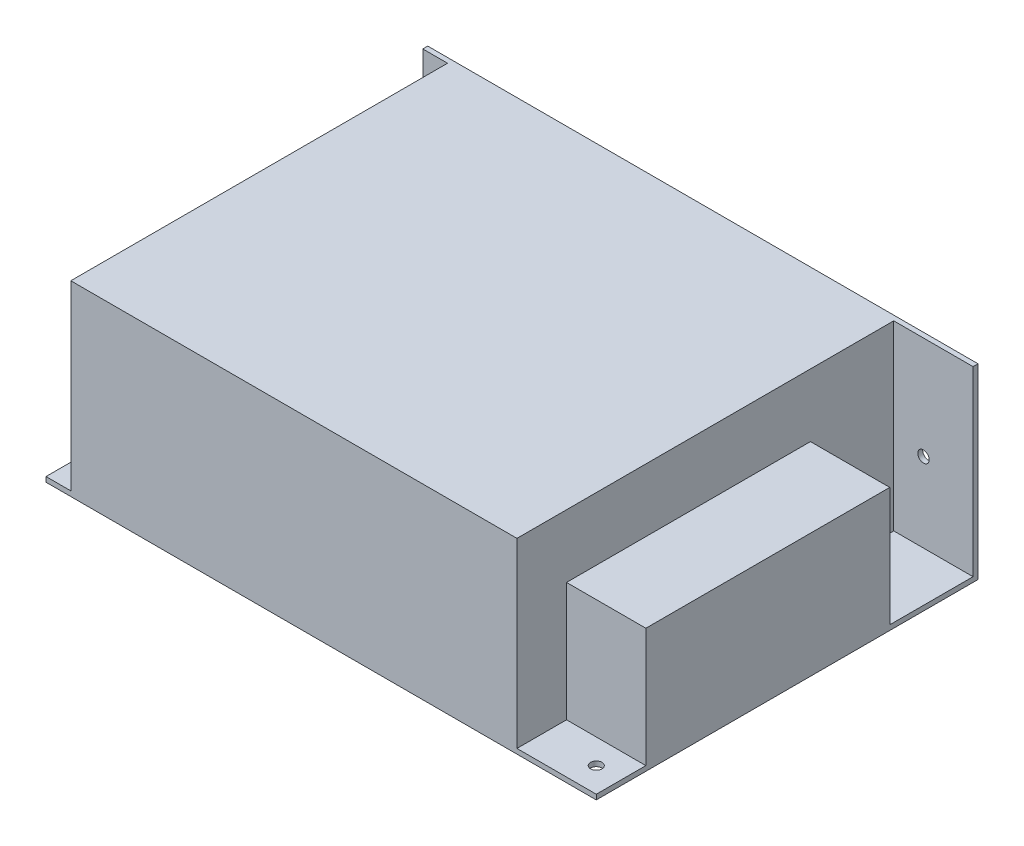
from build123d import *

# Parameters (mm, degrees)
ESBO_O1_W                = 111
ESBO_O1_H                = 77
RESSALTO_EXTRUS_O1_DEPTH = 1
ESBO_O2_W                = 111
ESBO_O2_H                = 1
RESSALTO_EXTRUS_O2_DEPTH = 36.7
ESBO_O3_W                = 90
ESBO_O3_H                = 76
RESSALTO_EXTRUS_O3_DEPTH = 36.7
ESBO_O4_W                = 16
ESBO_O4_H                = 49.2
RESSALTO_EXTRUS_O4_DEPTH = 24
ESBO_O5_R                = 1.15
CORTE_EXTRUS_O1_DEPTH    = 5
ESBO_O6_R                = 1.15
CORTE_EXTRUS_O2_DEPTH    = 5


with BuildPart() as part:
    # Esboço1 → Ressalto-extrusão1 (new body)
    with BuildSketch(Plane(origin=(0, 0, 0), x_dir=(1, 0, 0), z_dir=(0, 1, 0))):
        Rectangle(ESBO_O1_W, ESBO_O1_H)
    extrude(amount=RESSALTO_EXTRUS_O1_DEPTH)

    # Esboço2 → Ressalto-extrusão2 (add)
    with BuildSketch(Plane(origin=(0, 1, 0), x_dir=(1, 0, 0), z_dir=(0, 1, 0))):
        with Locations((0, 38)):
            Rectangle(ESBO_O2_W, ESBO_O2_H)
    extrude(amount=RESSALTO_EXTRUS_O2_DEPTH)

    # Esboço3 → Ressalto-extrusão3 (add)
    with BuildSketch(Plane(origin=(0, 1, 0), x_dir=(1, 0, 0), z_dir=(0, 1, 0))):
        with Locations((-5.5, -0.5)):
            Rectangle(ESBO_O3_W, ESBO_O3_H)
    extrude(amount=RESSALTO_EXTRUS_O3_DEPTH)

    # Esboço4 → Ressalto-extrusão4 (add)
    with BuildSketch(Plane(origin=(0, 1, 0), x_dir=(1, 0, 0), z_dir=(0, 1, 0))):
        with Locations((47.5, -3.9)):
            Rectangle(ESBO_O4_W, ESBO_O4_H)
    extrude(amount=RESSALTO_EXTRUS_O4_DEPTH)

    # Esboço5 → Corte-extrusão1 (cut)
    with BuildSketch(Plane(origin=(0, 0, -38.5), x_dir=(-1, 0, 0), z_dir=(0, 0, -1))):
        with Locations((-45.5, 17)):
            Circle(ESBO_O5_R)
        with Locations((43.5, 13)):
            Circle(ESBO_O5_R)
        with BuildLine():
            Line((55.5, 30.606515891), (52.6, 30.606515891))
            ThreePointArc((52.6, 30.606515891), (51, 29.006515891), (52.6, 27.406515891))
            Line((52.6, 27.406515891), (55.5, 27.406515891))
            Line((55.5, 27.406515891), (55.5, 30.606515891))
        make_face()
    extrude(amount=-CORTE_EXTRUS_O1_DEPTH, mode=Mode.SUBTRACT)

    # Esboço6 → Corte-extrusão2 (cut)
    with BuildSketch(Plane.XZ):
        with Locations((-42.5, 31.5)):
            Circle(ESBO_O6_R)
        with Locations((50.5, 33.5)):
            Circle(ESBO_O6_R)
        with Locations((-13, 13)):
            Circle(ESBO_O6_R)
        with Locations((23.5, 13.5)):
            Circle(ESBO_O6_R)
        with Locations((-13, -15)):
            Circle(ESBO_O6_R)
    extrude(amount=-CORTE_EXTRUS_O2_DEPTH, mode=Mode.SUBTRACT)


solid = part.part
